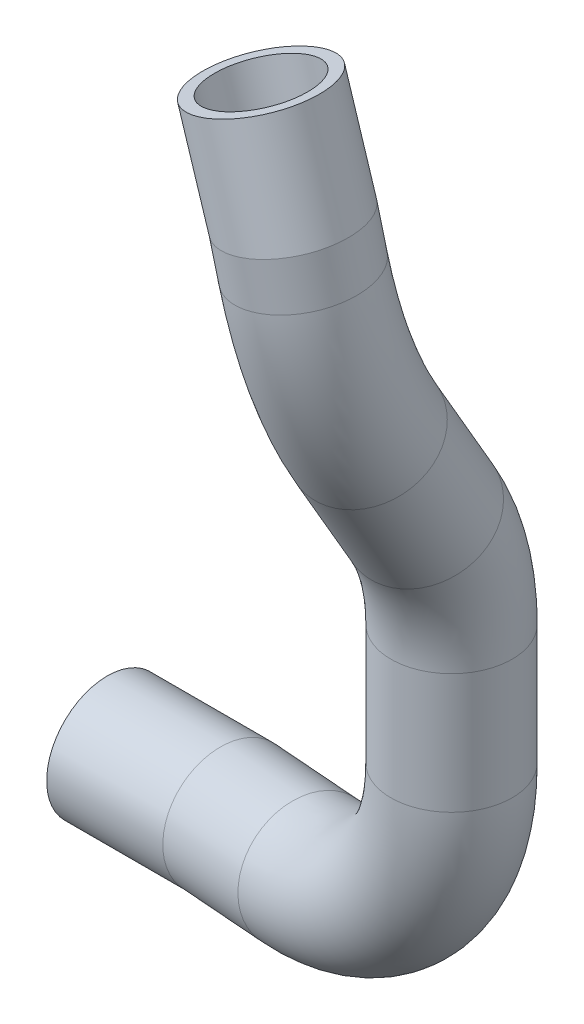
from build123d import *

# Parameters (mm, degrees)
WYCI_GNI_CIE_PO_CIE_CE_CIENKA_CIAN_2_R   = 12.5
WYCI_GNI_CIE_PO_CIE_CE_CIENKA_CIAN_2_R_2 = 10


with BuildPart() as part:
    # Wyciągnięcie po ścieżce-Cienka ścianka1: sweep along a curve in space
    with BuildLine() as wyci_gni_cie_po_cie_ce_cienka_cianka1_path:
        Line((1122.662673735, -353.960982393, 132.667073852), (1115.98547654, -333.159402404, 132.564775111))
        Line((1122.662673735, -353.960982393, 132.667073852), (1124.142619558, -362.624040315, 132.045026176))
        ThreePointArc((1126.481648306, -396.340241605, 121.320625575), (1126.250750355, -380.053322339, 128.683265614), (1124.142619558, -362.624040315, 132.045026176))
        Line((1126.481648306, -396.340241605, 121.320625575), (1125.495445206, -417.277359239, 108.741535608))
        ThreePointArc((1125.495445206, -417.277359239, 108.741535608), (1125.119230109, -428.450479714, 103.942885563), (1124.990693497, -440.504638353, 102.303392034))
        Line((1124.990693497, -465.256740445, 102.303392034), (1124.990693497, -440.504638353, 102.303392034))
        ThreePointArc((1124.990693497, -465.256740445, 102.303392034), (1114.765852609, -492.12664552, 100.581597466), (1089.392294835, -505.066121265, 96.308860666))
        Line((1069.71, -507.021686847, 92.994494339), (1089.392294835, -505.066121265, 96.308860666))
        Line((1044.71, -507.021686847, 92.994494339), (1069.71, -507.021686847, 92.994494339))
    # Wyci_gni_cie po _cie_ce-Cienka _cian 2 (on start of the path) → Wyciągnięcie po ścieżce-Cienka ścianka1 (sweep)
    with BuildSketch(Plane(origin=(1044.71, -507.021686847, 92.994494339), x_dir=(0, 0, 1), z_dir=(1, 0, 0))):
        Circle(WYCI_GNI_CIE_PO_CIE_CE_CIENKA_CIAN_2_R)
        Circle(WYCI_GNI_CIE_PO_CIE_CE_CIENKA_CIAN_2_R_2, mode=Mode.SUBTRACT)
    sweep(path=wyci_gni_cie_po_cie_ce_cienka_cianka1_path.line, transition=Transition.RIGHT)


solid = part.part
